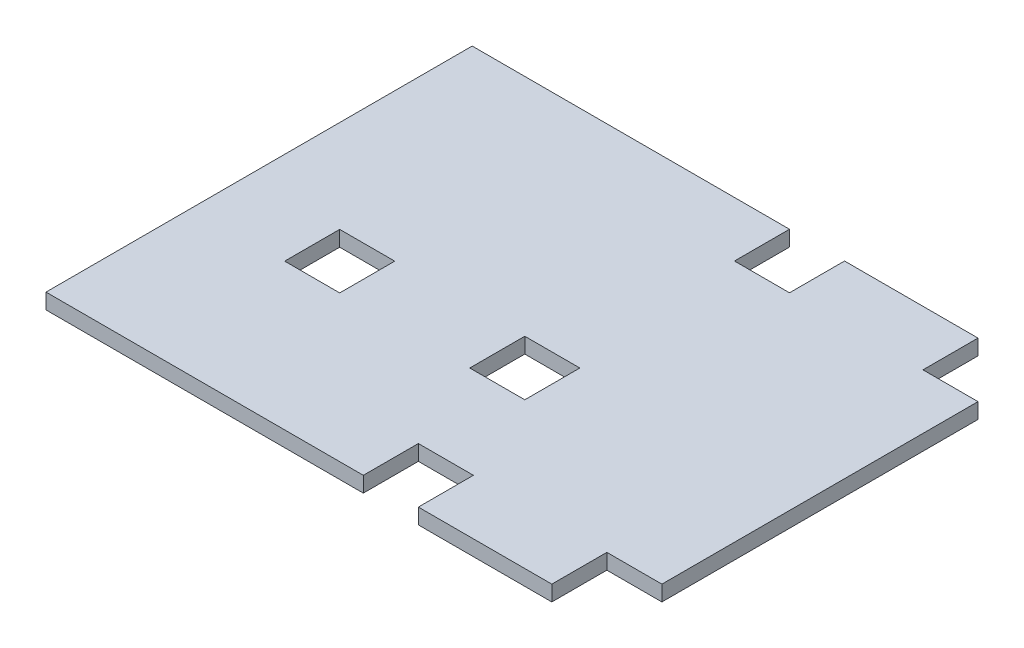
from build123d import *

# Parameters (mm, degrees)
SKETCH1_W           = 22.6
SKETCH1_H           = 22.6
BOSS_EXTRUDE1_DEPTH = 6.35


with BuildPart() as part:
    # Sketch1 → Boss-Extrude1 (new body)
    with BuildSketch(Plane(origin=(0, 0, 0), x_dir=(1, 0, 0), z_dir=(0, 1, 0))):
        Polygon((-100, 0), (-230.3, 0), (-230.3, -175), (-100, -175), (-100, -152.4), (-77.4, -152.4), (-77.4, -175), (-22.6, -175), (-22.6, -152.4), (0, -152.4), (0, -22.6), (-22.6, -22.6), (-22.6, 0), (-77.4, 0), (-77.4, -22.6), (-100, -22.6), align=None)
        with Locations((-181, -103.7)):
            Rectangle(SKETCH1_W, SKETCH1_H, mode=Mode.SUBTRACT)
        with Locations((-105, -103.7)):
            Rectangle(SKETCH1_W, SKETCH1_H, mode=Mode.SUBTRACT)
    extrude(amount=BOSS_EXTRUDE1_DEPTH)


solid = part.part
